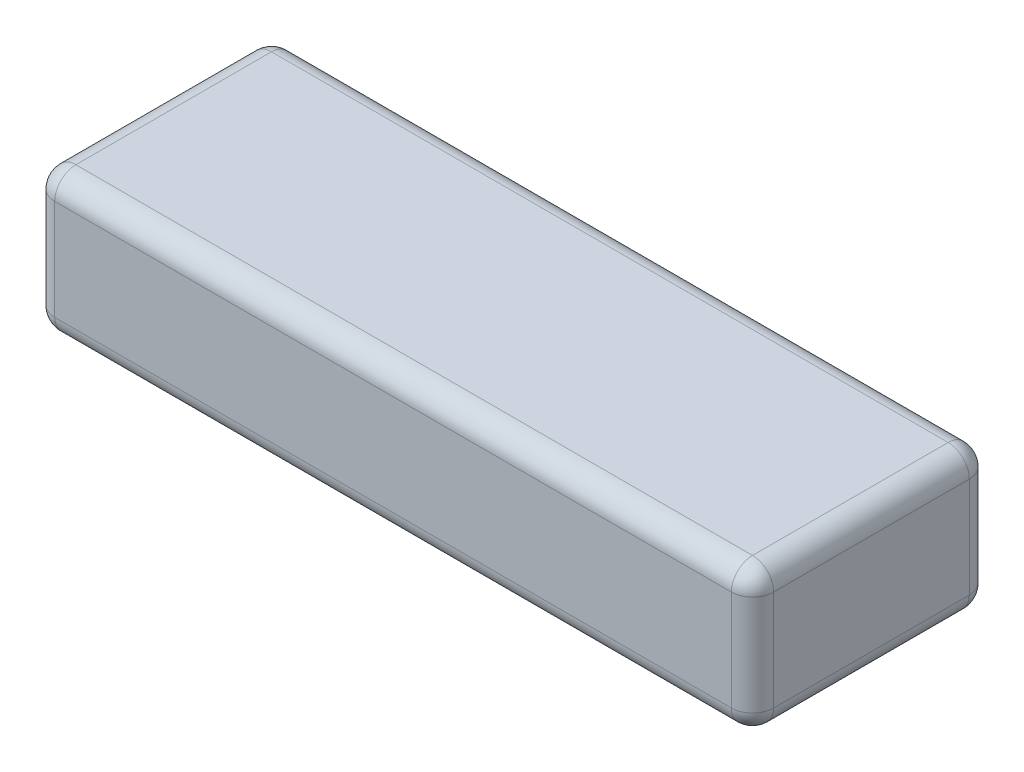
from build123d import *

# Parameters (mm, degrees)
CROQUIS1_W              = 136
CROQUIS1_H              = 45
SALIENTE_EXTRUIR1_DEPTH = 27
REDONDEO1_R             = 4


with BuildPart() as part:
    # Croquis1 → Saliente-Extruir1 (new body)
    with BuildSketch(Plane(origin=(0, 0, 0), x_dir=(1, 0, 0), z_dir=(0, 1, 0))):
        Rectangle(CROQUIS1_W, CROQUIS1_H)
    extrude(amount=SALIENTE_EXTRUIR1_DEPTH)

    # Redondeo1
    redondeo1_edges = [part.edges().sort_by_distance(p)[0] for p in [
        (-68, 27, 0),
        (0, 27, 22.5),
        (68, 27, 0),
        (0, 0, 22.5),
        (-68, 0, 0),
        (0, 0, -22.5),
        (68, 0, 0),
        (0, 27, -22.5),
        (68, 13.5, 22.5),
        (-68, 13.5, 22.5),
        (-68, 13.5, -22.5),
        (68, 13.5, -22.5),
    ]]
    fillet(redondeo1_edges, radius=REDONDEO1_R)


solid = part.part
